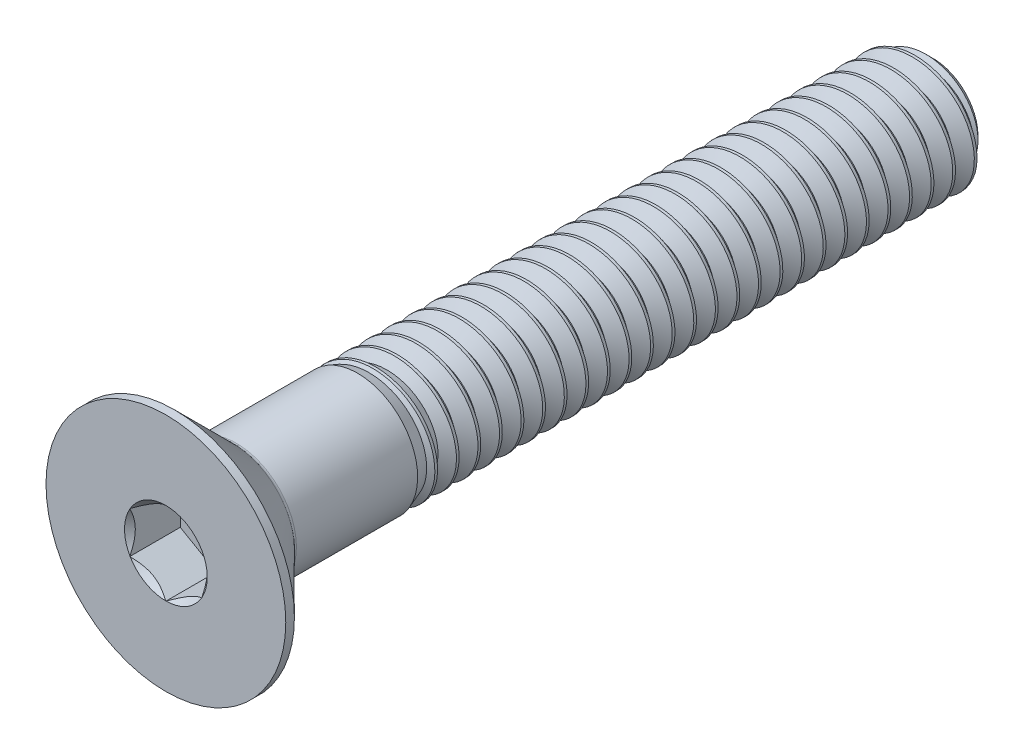
from build123d import *
from build123d.topology import SkipClean

# Parameters (mm, degrees)
CUT_EXTRUDE1_DEPTH            = 1.05
FILLET1_R                     = 0.1
CUT_SWEEP1_PITCH              = 0.45
CUT_SWEEP1_HEIGHT             = 12.45
CUT_SWEEP1_RADIUS             = 1.25
CUT_SWEEP1_START_ANGLE        = 90
SKETCH9_R                     = 1.25
BOSS_EXTRUDE1_DEPTH           = 0.9
BOSS_EXTRUDE1_OTHER_WAY_DEPTH = 1.35
BOSS_EXTRUDE1_OTHER_WAY_TAPER = 20


with BuildPart() as part:
    # Sketch4 → Revolve1 (revolve)
    with BuildSketch(Plane(origin=(0, 0, 0), x_dir=(0, 0, -1), z_dir=(1, 0, 0)), mode=Mode.PRIVATE) as revolve1_sk:
        Polygon((1.43, 1.25), (0.18, 2.5), (0, 2.5), (0, 0), (16, 0), (16, 0.935), (15.685, 1.25), align=None)
    revolve(revolve1_sk.sketch.rotate(Axis((0, 0, 0), (0, 0, -1)), 180), axis=Axis((0, 0, 0), (0, 0, -1)))

    # Sketch5 → Cut-Extrude1 (cut)
    with BuildSketch(Plane.XY):
        Polygon((-0.75, 0.433012702), (-0.75, -0.433012702), (0, -0.866025404), (0.75, -0.433012702), (0.75, 0.433012702), (0, 0.866025404), align=None)
    extrude(amount=-CUT_EXTRUDE1_DEPTH, mode=Mode.SUBTRACT)

    # Cut-Extrude2 cone 1 section (through the dimple's axis) → Cut-Extrude2 (revolve, cut)
    with BuildSketch(Plane(origin=(0, 0, 0), x_dir=(0, -1, 0), z_dir=(1, 0, 0))):
        Polygon((0, 0), (0.8625, 0), (0, 0.8625), align=None)
    revolve(axis=Axis((0, 0, 0), (0, 0, -1)), mode=Mode.SUBTRACT)

    # Fillet1
    fillet1_edges = [part.edges().sort_by_distance(p)[0] for p in [
        (0, 1.25, -1.43),
    ]]
    fillet(fillet1_edges, radius=FILLET1_R)

    # Cut-Sweep1: sweep along a helix
    with BuildLine() as cut_sweep1_path:
        add(Helix(CUT_SWEEP1_PITCH, CUT_SWEEP1_HEIGHT, CUT_SWEEP1_RADIUS, center=(0, 0, -16), direction=(0, 0, 1), mode=Mode.PRIVATE).rotate(Axis((0, 0, -16), (0, 0, 1)), CUT_SWEEP1_START_ANGLE))
    # Sketch7 → Cut-Sweep1 (sweep, cut)
    with BuildSketch(Plane(origin=(0, 0, 0), x_dir=(0, 0, -1), z_dir=(1, 0, 0))):
        Polygon((15.9859375, 1.274356964), (16.4078125, 1.274356964), (16.225, 0.957716426), (16.16875, 0.957716426), align=None)
    sweep(path=cut_sweep1_path.line, is_frenet=True, mode=Mode.SUBTRACT)

    # Sketch9 → Boss-Extrude1 (add)
    with SkipClean():  # the faces are left unmerged after this step: merging them gives an invalid solid
        with BuildSketch(Plane.XY.offset(-4)):
            with Locations(Location((0, 0, 0), (0, 0, 270))):
                Circle(SKETCH9_R)
        extrude(amount=BOSS_EXTRUDE1_DEPTH)

    # Sketch9 → Boss-Extrude1 other way (add)
    with SkipClean():  # the faces are left unmerged after this step: merging them gives an invalid solid
        with BuildSketch(Plane.XY.offset(-4)):
            with Locations(Location((0, 0, 0), (0, 0, 270))):
                Circle(SKETCH9_R)
        extrude(amount=-BOSS_EXTRUDE1_OTHER_WAY_DEPTH, taper=BOSS_EXTRUDE1_OTHER_WAY_TAPER)


solid = part.part
